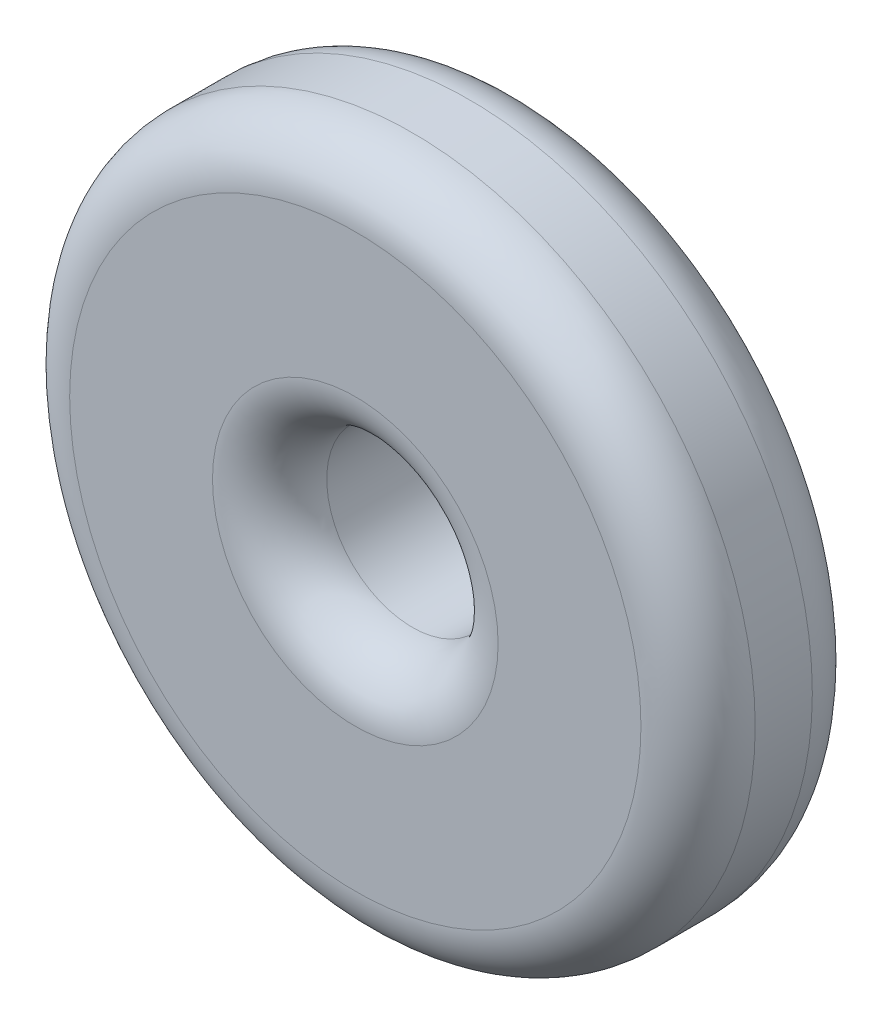
from build123d import *

# Parameters (mm, degrees)
SKETCH_1_R      = 6
SKETCH_1_R_2    = 1.5
EXTRUDE_1_DEPTH = 3
FILLET_2_R      = 1
FILLET_3_R      = 1


with BuildPart() as part:
    # 草图1 → 凸台-拉伸1 (new body)
    with BuildSketch(Plane.XY):
        Circle(SKETCH_1_R)
        Circle(SKETCH_1_R_2, mode=Mode.SUBTRACT)
    extrude(amount=EXTRUDE_1_DEPTH)

    # 圆角2
    fillet_2_edges = [part.edges().sort_by_distance(p)[0] for p in [
        (-6, 0, 0),
    ]]
    fillet(fillet_2_edges, radius=FILLET_2_R)

    # 圆角3
    fillet_3_edges = [part.edges().sort_by_distance(p)[0] for p in [
        (-6, 0, 3),
        (-1.5, 0, 3),
    ]]
    fillet(fillet_3_edges, radius=FILLET_3_R)


solid = part.part
